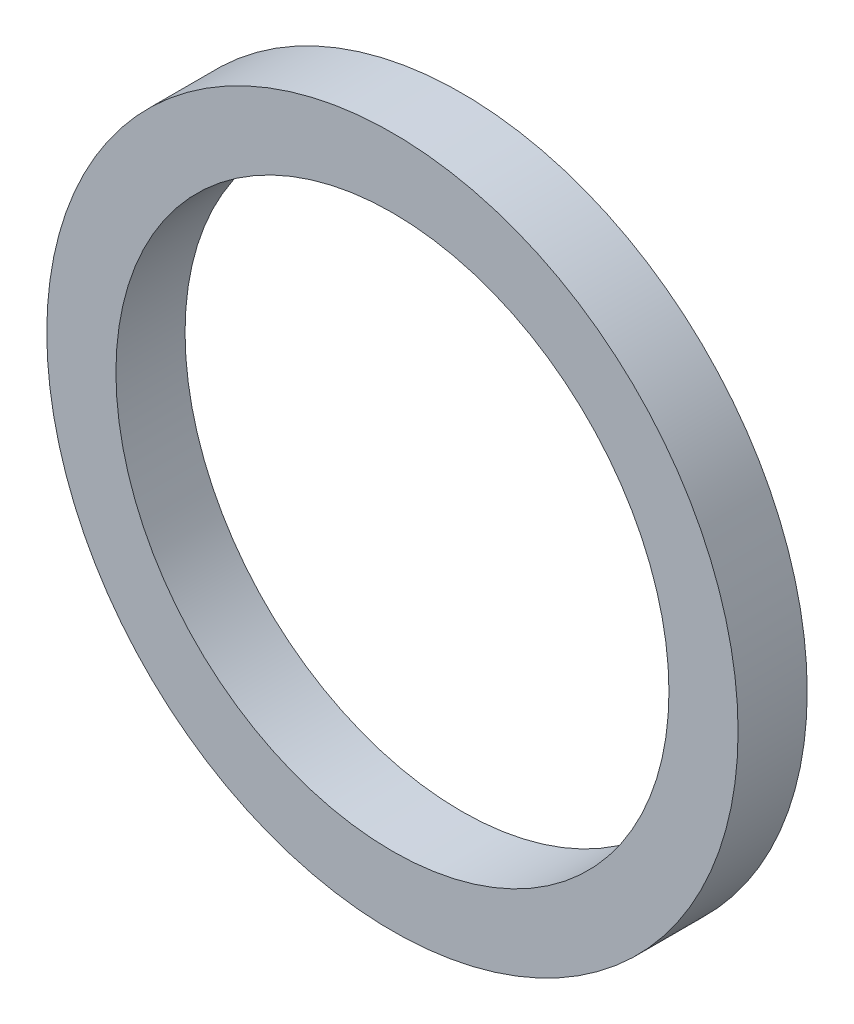
from build123d import *

# Parameters (mm, degrees)
SKETCH_1_R      = 50
SKETCH_1_R_2    = 40
EXTRUDE_1_DEPTH = 10


with BuildPart() as part:
    # 草图1 → 凸台-拉伸1 (new body)
    with BuildSketch(Plane.XY):
        Circle(SKETCH_1_R)
        Circle(SKETCH_1_R_2, mode=Mode.SUBTRACT)
    extrude(amount=EXTRUDE_1_DEPTH)


solid = part.part
